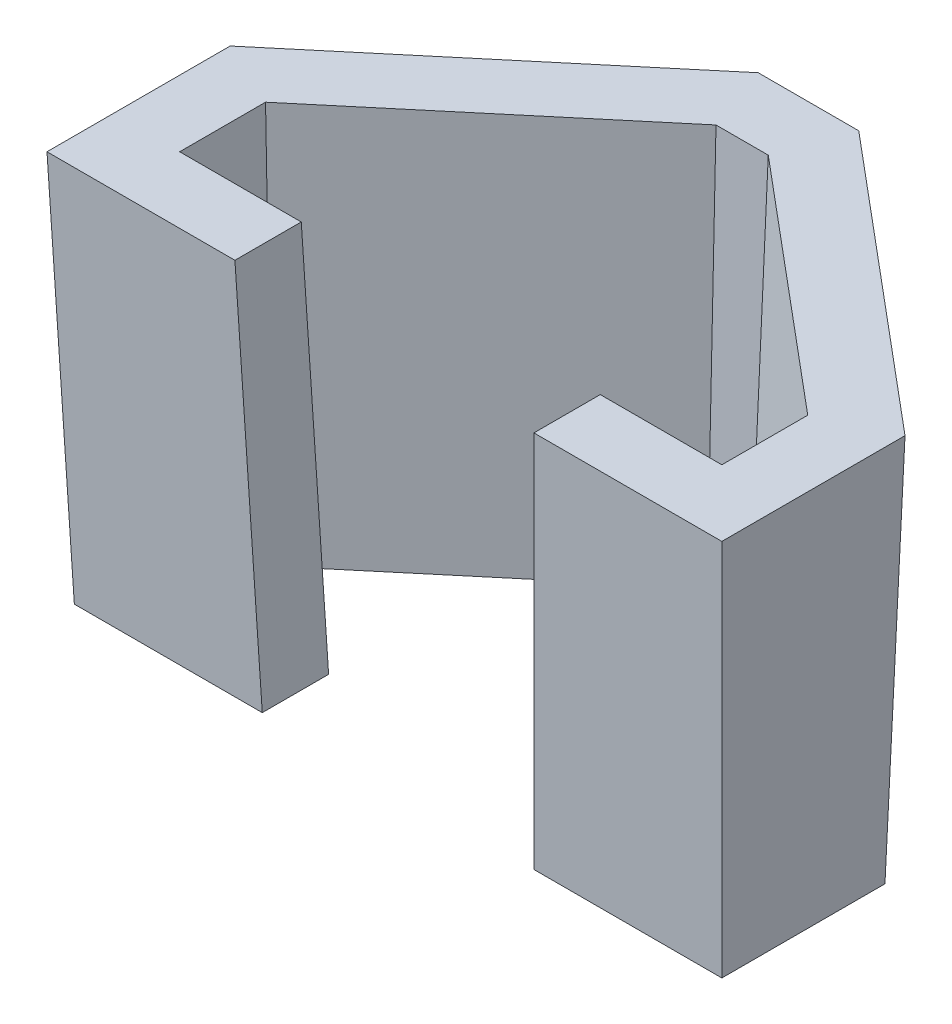
from build123d import *

# Parameters (mm, degrees)
SALIENTE_EXTRUIR1_DEPTH = 8
SALIENTE_EXTRUIR1_TAPER = -2
SALIENTE_EXTRUIR3_DEPTH = 75
SALIENTE_EXTRUIR3_TAPER = -2
CORTAR_EXTRUIR3_DEPTH   = 76.0000001
CORTAR_EXTRUIR3_TAPER   = -2
CROQUIS14_W             = 52
CROQUIS14_H             = 12.7
CORTAR_EXTRUIR4_DEPTH   = 76.0000001
CORTAR_EXTRUIR4_TAPER   = -2


with BuildPart() as part:
    # Croquis1 → Saliente-Extruir1 (new body)
    with BuildSketch(Plane(origin=(0, 0, 0), x_dir=(1, 0, 0), z_dir=(0, 1, 0))):
        Polygon((0, 0), (98.55, 0), (98.55, 12.6), (53.325, 50.537320346), (45.225, 50.537320346), (0, 12.6), align=None)
    extrude(amount=SALIENTE_EXTRUIR1_DEPTH, taper=SALIENTE_EXTRUIR1_TAPER)

    # Croquis10 → Saliente-Extruir3 (add)
    with BuildSketch(Plane.XZ):
        Polygon((-12.7, 12.7), (-12.7, -18.52320689), (40.60360085, -63.237320346), (57.94639915, -63.237320346), (111.25, -18.52320689), (111.25, 12.7), align=None)
    extrude(amount=-SALIENTE_EXTRUIR3_DEPTH, taper=SALIENTE_EXTRUIR3_TAPER)

    # Croquis11 → Cortar-Extruir3 (cut, through all)
    with BuildSketch(Plane.XZ):
        Polygon((98.55, 0), (0, 0), (0, -12.6), (45.225, -50.537320346), (53.325, -50.537320346), (98.55, -12.6), align=None)
    extrude(amount=-CORTAR_EXTRUIR3_DEPTH, taper=CORTAR_EXTRUIR3_TAPER, mode=Mode.SUBTRACT)

    # Croquis14 → Cortar-Extruir4 (cut, through all)
    with BuildSketch(Plane.XZ):
        with Locations((49.275, 6.35)):
            Rectangle(CROQUIS14_W, CROQUIS14_H)
    extrude(amount=-CORTAR_EXTRUIR4_DEPTH, taper=CORTAR_EXTRUIR4_TAPER, mode=Mode.SUBTRACT)


solid = part.part
